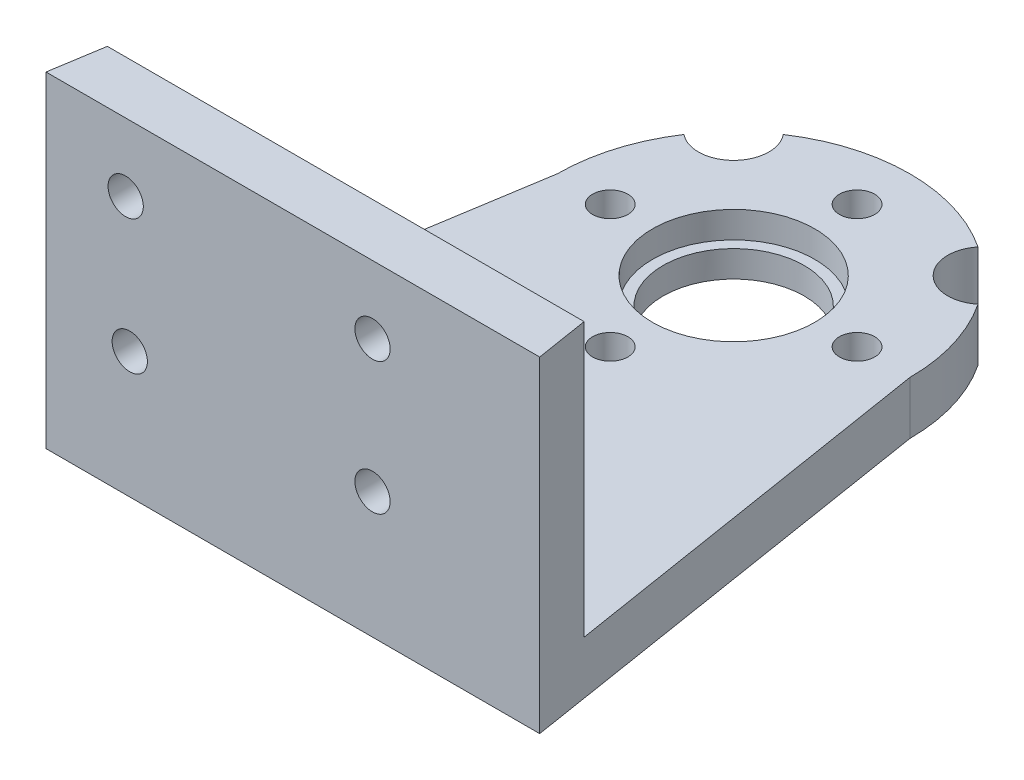
from build123d import *

# Parameters (mm, degrees)
BOSS_EXTRUDE1_DEPTH = 3
SKETCH2_R           = 4
CUT_EXTRUDE1_DEPTH  = 13
SKETCH3_R           = 1
CUT_EXTRUDE2_DEPTH  = 13
SKETCH4_R           = 1
CUT_EXTRUDE3_DEPTH  = 3
BOSS_EXTRUDE2_DEPTH = 15.5
SKETCH6_R           = 4.6
CUT_EXTRUDE4_DEPTH  = 1.5
SKETCH7_R           = 2
CUT_EXTRUDE5_DEPTH  = 10
SKETCH8_R           = 1
CUT_EXTRUDE6_DEPTH  = 10


with BuildPart() as part:
    # Sketch1 → Boss-Extrude1 (new body)
    with BuildSketch(Plane(origin=(0, 0, 0), x_dir=(1, 0, 0), z_dir=(0, 1, 0))):
        with BuildLine():
            Line((-10, 0), (-14, -25))
            Line((-14, -25), (14, -25))
            Line((14, -25), (10, 0))
            ThreePointArc((10, 0), (0, 10), (-10, 0))
        make_face()
    extrude(amount=BOSS_EXTRUDE1_DEPTH)

    # Sketch2 → Cut-Extrude1 (cut)
    with BuildSketch(Plane(origin=(0, 3, 0), x_dir=(1, 0, 0), z_dir=(0, 1, 0))):
        Circle(SKETCH2_R)
    extrude(amount=-CUT_EXTRUDE1_DEPTH, mode=Mode.SUBTRACT)

    # Sketch3 → Cut-Extrude2 (cut)
    with BuildSketch(Plane(origin=(0, 3, 0), x_dir=(1, 0, 0), z_dir=(0, 1, 0))):
        with Locations((-6.52, -19)):
            Circle(SKETCH3_R)
        with Locations((6.52, -19)):
            Circle(SKETCH3_R)
        with Locations((0, -19)):
            Circle(SKETCH3_R)
    extrude(amount=-CUT_EXTRUDE2_DEPTH, mode=Mode.SUBTRACT)

    # Sketch4 → Cut-Extrude3 (cut)
    with BuildSketch(Plane(origin=(0, 3, 0), x_dir=(1, 0, 0), z_dir=(0, 1, 0))):
        with Locations((0, -7)):
            Circle(SKETCH4_R)
        with Locations((-7, 0)):
            Circle(SKETCH4_R)
        with Locations((0, 7)):
            Circle(SKETCH4_R)
        with Locations((7, 0)):
            Circle(SKETCH4_R)
    extrude(amount=-CUT_EXTRUDE3_DEPTH, mode=Mode.SUBTRACT)

    # Sketch5 → Boss-Extrude2 (add)
    with BuildSketch(Plane(origin=(0, 3, 0), x_dir=(1, 0, 0), z_dir=(0, 1, 0))):
        Polygon((-13.52, -22), (13.52, -22), (14, -25), (-14, -25), align=None)
    extrude(amount=BOSS_EXTRUDE2_DEPTH)

    # Sketch6 → Cut-Extrude4 (cut)
    with BuildSketch(Plane(origin=(0, 3, 0), x_dir=(1, 0, 0), z_dir=(0, 1, 0))):
        Circle(SKETCH6_R)
    extrude(amount=-CUT_EXTRUDE4_DEPTH, mode=Mode.SUBTRACT)

    # Sketch7 → Cut-Extrude5 (cut)
    with BuildSketch(Plane(origin=(0, 3, 0), x_dir=(1, 0, 0), z_dir=(0, 1, 0))):
        with Locations((-7.071067812, 7.071067812)):
            Circle(SKETCH7_R)
        with Locations((7.071067812, 7.071067812)):
            Circle(SKETCH7_R)
    extrude(amount=-CUT_EXTRUDE5_DEPTH, mode=Mode.SUBTRACT)

    # Sketch8 → Cut-Extrude6 (cut)
    with BuildSketch(Plane(origin=(0, 0, 22), x_dir=(-1, 0, 0), z_dir=(0, 0, -1))):
        with Locations((-4.518775135, 7.151837118)):
            Circle(SKETCH8_R)
        with Locations((-4.518775135, 14.651837118)):
            Circle(SKETCH8_R)
        with Locations((9.481224865, 14.651837118)):
            Circle(SKETCH8_R)
        with Locations((9.248832445, 7.151837118)):
            Circle(SKETCH8_R)
    extrude(amount=-CUT_EXTRUDE6_DEPTH, mode=Mode.SUBTRACT)


solid = part.part
